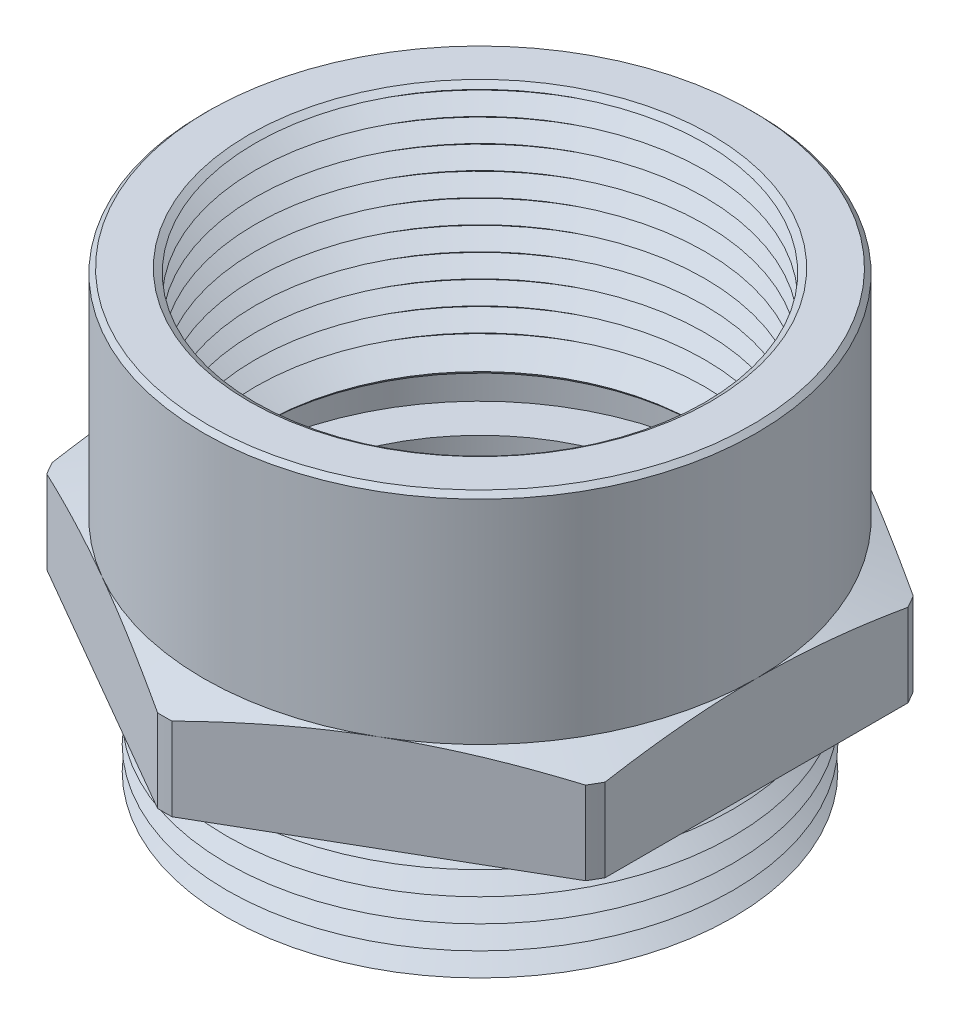
from build123d import *

# Parameters (mm, degrees)
SKETCH2_OUTSIDE_W  = 46.948
SKETCH2_OUTSIDE_H  = 46.948
CUT_EXTRUDE1_DEPTH = 18.018
SKETCH4_OUTSIDE_W  = 49.218
SKETCH4_OUTSIDE_H  = 53.414
SKETCH4_OUTSIDE_R  = 14.986
CUT_EXTRUDE3_DEPTH = 1.27
CUT_EXTRUDE3_DRAFT = -70
CHAMFER2_SIZE      = 0.247603347
CHAMFER2_SIZE2     = 0.254
LPATTERN1_COUNT    = 11
LPATTERN1_PITCH    = 1.27
LPATTERN2_COUNT    = 6
LPATTERN2_PITCH    = 1.27
CHAMFER3_SIZE      = 0.254


with BuildPart() as part:
    # Sketch1 → Revolve1 (revolve)
    with BuildSketch(Plane.XY, mode=Mode.PRIVATE) as revolve1_sk:
        Polygon((11.2776, 0), (13.91741695, 0), (14.097, 6.858), (17.08404, 6.858), (17.08404, 12.11072), (14.986, 12.11072), (14.986, 23.876), (12.124749754, 23.876), (11.7729, 10.4394), (13.538835, 10.4394), (13.538835, 8.0518), (11.2776, 8.0518), align=None)
    revolve(revolve1_sk.sketch.rotate(Axis((0, 0, 0), (0, 1, 0)), 90), axis=Axis((0, 0, 0), (0, 1, 0)))  # turned: the seam where the file's is

    # Sketch2 outside → Cut-Extrude1 (cut, through all)
    with BuildSketch(Plane.XZ.offset(-6.858)):
        Rectangle(SKETCH2_OUTSIDE_W, SKETCH2_OUTSIDE_H)
        Polygon((14.986, 8.652171134), (0, 17.304342268), (-14.986, 8.652171134), (-14.986, -8.652171134), (0, -17.304342268), (14.986, -8.652171134), align=None, mode=Mode.SUBTRACT)
    extrude(amount=-CUT_EXTRUDE1_DEPTH, mode=Mode.SUBTRACT)


with BuildPart() as cut_extrude3_tool:
    # Sketch4 outside → Cut-Extrude3 (with draft: the straight prism first)
    with BuildSketch(Plane(origin=(0, 12.11072, 0), x_dir=(-1, 0, 0), z_dir=(0, 1, 0))):
        Rectangle(SKETCH4_OUTSIDE_W, SKETCH4_OUTSIDE_H)
        with Locations(Location((0, 0, 0), (0, 0, 270))):  # turned: the seam where the file's is
            Circle(SKETCH4_OUTSIDE_R, mode=Mode.SUBTRACT)
    extrude(amount=-CUT_EXTRUDE3_DEPTH)
    # Cut-Extrude3: the draft: its side faces are tilted about the plane it starts from
    cut_extrude3_sides = [cut_extrude3_tool.faces().sort_by_distance(p)[0] for p in [
        (0, 11.47572, -26.707),
        (-24.609, 11.47572, 0),
        (0, 11.47572, 26.707),
        (24.609, 11.47572, 0),
        (0, 11.47572, 14.986),
    ]]
    draft(cut_extrude3_sides, Plane(origin=(0, 12.11072, 0), x_dir=(-1, 0, 0), z_dir=(0, 1, 0)), CUT_EXTRUDE3_DRAFT)


with BuildPart() as part_1:
    add(part.part)

    # Cut-Extrude3: cut by cut_extrude3_tool
    add(cut_extrude3_tool.part, mode=Mode.SUBTRACT)

    # Chamfer2
    chamfer2_edges = [part_1.edges().sort_by_distance(p)[0] for p in [
        (0, 10.4394, 11.7729),
    ]]
    chamfer2_side = [part_1.faces().sort_by_distance(p)[0] for p in [
        (0, 17.1577, 11.948824877),
    ]]
    chamfer(chamfer2_edges, length=CHAMFER2_SIZE, length2=CHAMFER2_SIZE2, reference=chamfer2_side[0])

    # Sketch7 → Cut-Revolve1 (revolve, cut)
    with BuildSketch(Plane.XY, mode=Mode.PRIVATE) as cut_revolve1_sk:
        Polygon((-11.7793815, 10.6869185), (-11.826253926, 12.476904245), (-13.081, 11.548440991), align=None)
    cut_revolve1 = revolve(cut_revolve1_sk.sketch.rotate(Axis((0, 0, 0), (0, 1, 0)), 270), axis=Axis((0, 0, 0), (0, 1, 0)), mode=Mode.SUBTRACT)  # turned: the seam where the file's is

    # LPattern1: Cut-Revolve1 ×11
    with Locations(*[(0, i * LPATTERN1_PITCH, 0) for i in range(1, LPATTERN1_COUNT)]):
        add(cut_revolve1, mode=Mode.SUBTRACT)

    # Sketch8 → Cut-Revolve2 (revolve, cut)
    with BuildSketch(Plane.XY, mode=Mode.PRIVATE) as cut_revolve2_sk:
        Polygon((-14.097, 6.858), (-12.804156991, 6.002285879), (-14.050443587, 5.08008231), align=None)
    cut_revolve2 = revolve(cut_revolve2_sk.sketch.rotate(Axis((0, 0, 0), (0, 1, 0)), 270), axis=Axis((0, 0, 0), (0, 1, 0)), mode=Mode.SUBTRACT)  # turned: the seam where the file's is

    # LPattern2: Cut-Revolve2 ×6
    with Locations(*[(0, -i * LPATTERN2_PITCH, 0) for i in range(1, LPATTERN2_COUNT)]):
        add(cut_revolve2, mode=Mode.SUBTRACT)

    # Chamfer3
    chamfer3_edges = [part_1.edges().sort_by_distance(p)[0] for p in [
        (0, 23.876, 14.986),
    ]]
    chamfer(chamfer3_edges, length=CHAMFER3_SIZE)


solid = part_1.part
